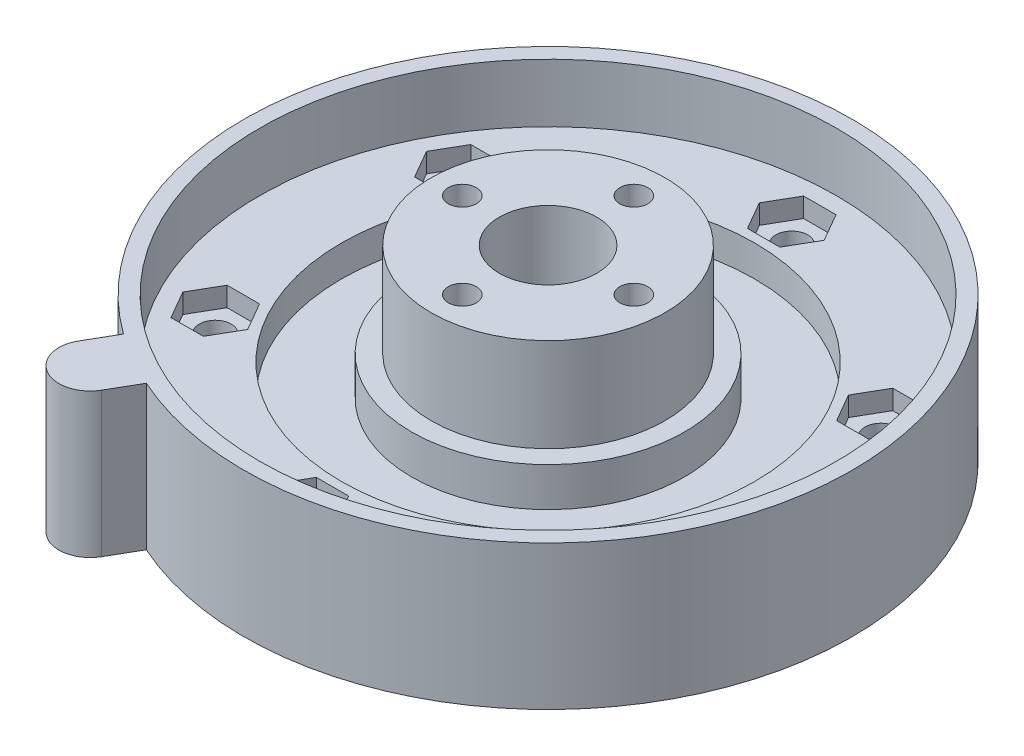
from build123d import *

# Parameters (mm, degrees)
SKETCH1_R                                           = 39
BOSS_EXTRUDE1_DEPTH                                 = 18.5
SKETCH2_R                                           = 37
CUT_EXTRUDE1_DEPTH                                  = 7.5
SKETCH3_R                                           = 26.5
CUT_EXTRUDE2_DEPTH                                  = 4
SKETCH4_R                                           = 17.5
BOSS_EXTRUDE2_DEPTH                                 = 5
SKETCH5_R                                           = 15
BOSS_EXTRUDE3_DEPTH                                 = 12
SKETCH6_R                                           = 6.25
SKETCH6_R_2                                         = 1.8
CUT_EXTRUDE3_DEPTH                                  = 25
CSK_FOR_M4_COUNTERSUNK_FLAT_HEAD_SCREW1_D           = 3.5
CSK_FOR_M4_COUNTERSUNK_FLAT_HEAD_SCREW1_CSINK_D     = 9.1
CSK_FOR_M4_COUNTERSUNK_FLAT_HEAD_SCREW1_CSINK_ANGLE = 90
SKETCH9_R                                           = 2.05
CUT_EXTRUDE4_DEPTH                                  = 12.0000001
CUT_EXTRUDE5_DEPTH                                  = 2.5
CIRPATTERN1_COUNT                                   = 6
SKETCH11_R                                          = 4
BOSS_EXTRUDE5_DEPTH                                 = 18.5


with BuildPart() as part:
    # Sketch1 → Boss-Extrude1 (new body)
    with BuildSketch(Plane(origin=(0, 0, 0), x_dir=(1, 0, 0), z_dir=(0, 1, 0))):
        Circle(SKETCH1_R)
    extrude(amount=BOSS_EXTRUDE1_DEPTH)

    # Sketch2 → Cut-Extrude1 (cut)
    with BuildSketch(Plane(origin=(0, 18.5, 0), x_dir=(1, 0, 0), z_dir=(0, 1, 0))):
        Circle(SKETCH2_R)
    extrude(amount=-CUT_EXTRUDE1_DEPTH, mode=Mode.SUBTRACT)

    # Sketch3 → Cut-Extrude2 (cut)
    with BuildSketch(Plane(origin=(0, 11, 0), x_dir=(1, 0, 0), z_dir=(0, 1, 0))):
        Circle(SKETCH3_R)
    extrude(amount=-CUT_EXTRUDE2_DEPTH, mode=Mode.SUBTRACT)

    # Sketch4 → Boss-Extrude2 (add)
    with BuildSketch(Plane(origin=(0, 7, 0), x_dir=(1, 0, 0), z_dir=(0, 1, 0))):
        Circle(SKETCH4_R)
    extrude(amount=BOSS_EXTRUDE2_DEPTH)

    # Sketch5 → Boss-Extrude3 (add)
    with BuildSketch(Plane(origin=(0, 12, 0), x_dir=(1, 0, 0), z_dir=(0, 1, 0))):
        Circle(SKETCH5_R)
    extrude(amount=BOSS_EXTRUDE3_DEPTH)

    # Sketch6 → Cut-Extrude3 (cut, through all)
    with BuildSketch(Plane(origin=(0, 24, 0), x_dir=(1, 0, 0), z_dir=(0, 1, 0))):
        Circle(SKETCH6_R)
        with Locations((0, 11)):
            Circle(SKETCH6_R_2)
        with Locations((11, 0)):
            Circle(SKETCH6_R_2)
        with Locations((0, -11)):
            Circle(SKETCH6_R_2)
        with Locations((-11, 0)):
            Circle(SKETCH6_R_2)
    extrude(amount=-CUT_EXTRUDE3_DEPTH, mode=Mode.SUBTRACT)

    # CSK for M4 Countersunk Flat Head Screw1 (through all)
    with Locations(Plane(origin=(0, 0, 11), x_dir=(0, 0, -1), z_dir=(0, -1, 0))):
        with Locations((0, 0), (11, 11), (22, 0), (11, -11)):
            CounterSinkHole(CSK_FOR_M4_COUNTERSUNK_FLAT_HEAD_SCREW1_D / 2, CSK_FOR_M4_COUNTERSUNK_FLAT_HEAD_SCREW1_CSINK_D / 2, counter_sink_angle=CSK_FOR_M4_COUNTERSUNK_FLAT_HEAD_SCREW1_CSINK_ANGLE)

    # Sketch9 → Cut-Extrude4 (cut, through all)
    with BuildSketch(Plane(origin=(0, 11, 0), x_dir=(1, 0, 0), z_dir=(0, 1, 0))):
        with Locations((0, 31.25)):
            Circle(SKETCH9_R)
        with Locations((27.063293868, 15.625)):
            Circle(SKETCH9_R)
        with Locations((27.063293868, -15.625)):
            Circle(SKETCH9_R)
        with Locations((0, -31.25)):
            Circle(SKETCH9_R)
        with Locations((-27.063293868, -15.625)):
            Circle(SKETCH9_R)
        with Locations((-27.063293868, 15.625)):
            Circle(SKETCH9_R)
    extrude(amount=-CUT_EXTRUDE4_DEPTH, mode=Mode.SUBTRACT)

    # Sketch10 → Cut-Extrude5 (cut)
    with BuildSketch(Plane(origin=(0, 11, 0), x_dir=(1, 0, 0), z_dir=(0, 1, 0))):
        Polygon((2.078460969, 34.85), (-2.078460969, 34.85), (-4.156921938, 31.25), (-2.078460969, 27.65), (2.078460969, 27.65), (4.156921938, 31.25), align=None)
    cut_extrude5 = extrude(amount=-CUT_EXTRUDE5_DEPTH, mode=Mode.SUBTRACT)

    # CirPattern1: Cut-Extrude5 ×6 about axis
    cirpattern1_axis = Axis((0, 0, 0), (0, 1, 0))
    for i in range(1, CIRPATTERN1_COUNT):
        add(cut_extrude5.rotate(cirpattern1_axis, i * 360 / CIRPATTERN1_COUNT), mode=Mode.SUBTRACT)

    # Sketch11 → Boss-Extrude5 (add, through all)
    with BuildSketch(Plane(origin=(0, 18.5, 0), x_dir=(1, 0, 0), z_dir=(0, 1, 0))):
        with Locations((-21.5, -37.239092363)):
            Circle(SKETCH11_R)
        with BuildLine():
            ThreePointArc((-17.5, -37.239092363), (-17.636296695, -38.274368543), (-18.035898385, -39.239092363))
            Line((-18.035898385, -39.239092363), (-15.933063126, -35.596874855))
            ThreePointArc((-15.933063126, -35.596874855), (-17.739935267, -34.731753436), (-19.499999848, -33.774990835))
            ThreePointArc((-19.499999848, -33.774990835), (-18.035898341, -35.239092439), (-17.5, -37.239092363))
        make_face()
        with BuildLine():
            Line((-22.861266356, -31.596874855), (-24.964101615, -35.239092363))
            ThreePointArc((-24.964101615, -35.239092363), (-22.535276096, -33.375389035), (-19.499999848, -33.774990835))
            ThreePointArc((-19.499999848, -33.774990835), (-21.208613012, -32.729111416), (-22.861266356, -31.596874855))
        make_face()
    extrude(amount=-BOSS_EXTRUDE5_DEPTH)


solid = part.part
